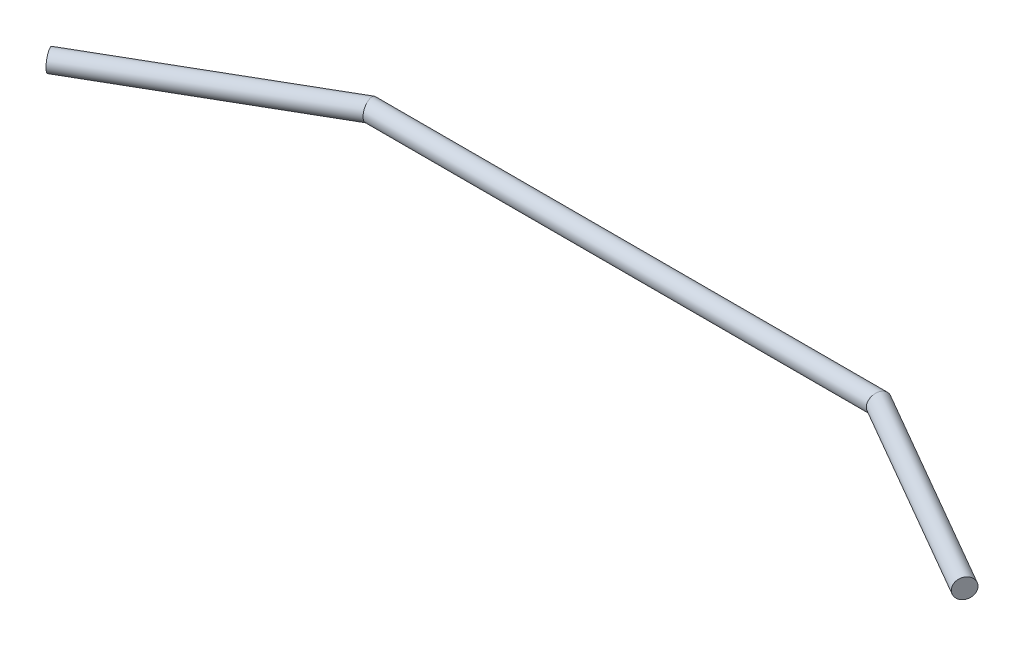
from build123d import *

# Parameters (mm, degrees)
VARREDURA1_PROFILE_R = 1.25


with BuildPart() as part:
    # Varredura1: sweep along a path in Esboço8
    with BuildLine(Plane(origin=(0, 0, 0), x_dir=(1, 0, 0), z_dir=(0, 1, 0))) as varredura1_path:
        Line((58.480762114, -15), (32.5, 0))
        Line((32.5, 0), (-32.5, 0))
        Line((-32.5, 0), (-58.480762114, -15))
    # Varredura1 profile (on start of the path) → Varredura1 (sweep)
    with BuildSketch(Plane(origin=(58.480762114, 0, 15), x_dir=(0.5, 0, -0.866025404), z_dir=(-0.866025404, 0, -0.5))):
        Circle(VARREDURA1_PROFILE_R)
    sweep(path=varredura1_path.line, transition=Transition.RIGHT)


solid = part.part
